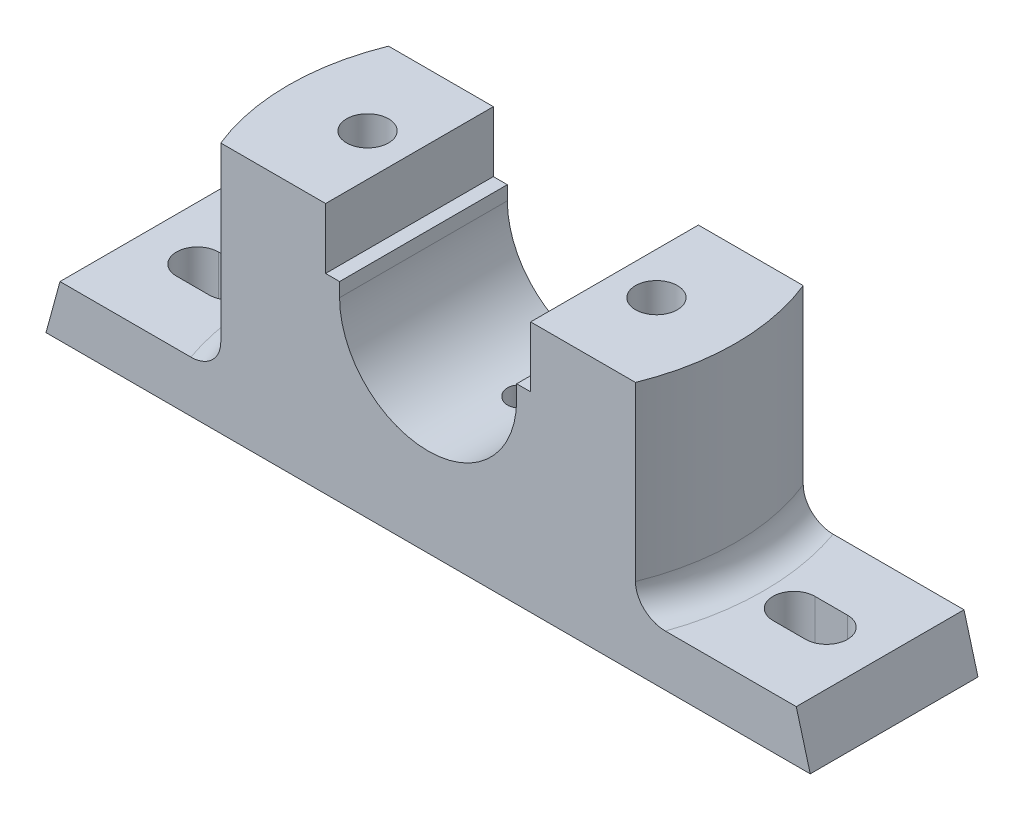
from build123d import *

# Parameters (mm, degrees)
BOSS_EXTRUDE1_DEPTH       = 18
CUT_EXTRUDE2_DEPTH        = 43
CUT_EXTRUDE3_DEPTH        = 11
SKETCH6_W                 = 20
SKETCH6_H                 = 20
CUT_EXTRUDE4_DEPTH        = 8
F_6_0MM_DOWEL_HOLE2_D     = 9
FILLET1_R                 = 6
FILLET2_R                 = 6
F_6_0MM_DOWEL_HOLE3_D     = 6
F_6_0MM_DOWEL_HOLE3_DEPTH = 6
F_6_0MM_DOWEL_HOLE3_TIP   = 1.802581857


with BuildPart() as part:
    # Sketch2 → Boss-Extrude1 (new, symmetric)
    with BuildSketch(Plane.XY):
        with BuildLine():
            Line((-82, 0), (82, 0))
            Line((82, 0), (79, 11))
            Line((79, 11), (50, 11))
            Line((50, 11), (50, 54))
            Line((50, 54), (22, 54))
            Line((22, 54), (22, 41))
            Line((22, 41), (19, 41))
            Line((19, 41), (19, 38))
            ThreePointArc((19, 38), (0, 19), (-19, 38))
            Line((-19, 38), (-19, 41))
            Line((-19, 41), (-22, 41))
            Line((-22, 41), (-22, 54))
            Line((-22, 54), (-50, 54))
            Line((-50, 54), (-50, 11))
            Line((-50, 11), (-79, 11))
            Line((-79, 11), (-82, 0))
        make_face()
    extrude(amount=BOSS_EXTRUDE1_DEPTH, both=True)

    # Sketch3 → Cut-Extrude2 (cut)
    with BuildSketch(Plane(origin=(0, 54, 0), x_dir=(1, 0, 0), z_dir=(0, 1, 0))):
        with BuildLine():
            Line((-44.497190923, -18), (-50, -18))
            Line((-50, -18), (-50, 18))
            Line((-50, 18), (-44.497190923, 18))
            ThreePointArc((-44.497190923, 18), (-48, 0), (-44.497190923, -18))
        make_face()
    cut_extrude2 = extrude(amount=-CUT_EXTRUDE2_DEPTH, mode=Mode.SUBTRACT)

    # Sketch4 → Cut-Extrude3 (cut)
    with BuildSketch(Plane(origin=(0, 11, 0), x_dir=(1, 0, 0), z_dir=(0, 1, 0))):
        with BuildLine():
            Line((-67.5, 4.5), (-60.5, 4.5))
            ThreePointArc((-60.5, 4.5), (-56, 0), (-60.5, -4.5))
            Line((-60.5, -4.5), (-67.5, -4.5))
            ThreePointArc((-67.5, -4.5), (-72, 0), (-67.5, 4.5))
        make_face()
    cut_extrude3 = extrude(amount=-CUT_EXTRUDE3_DEPTH, mode=Mode.SUBTRACT)

    # Sketch6 → Cut-Extrude4 (cut)
    with BuildSketch(Plane.XZ):
        with Locations((-31, 0)):
            Rectangle(SKETCH6_W, SKETCH6_H)
    cut_extrude4 = extrude(amount=-CUT_EXTRUDE4_DEPTH, mode=Mode.SUBTRACT)

    # Ø6.0mm Dowel Hole2 (through all)
    with Locations(Plane(origin=(0, 8, 0), x_dir=(-1, 0, 0), z_dir=(0, -1, 0))):
        with Locations((31, 0)):
            f_6_0mm_dowel_hole2 = Hole(F_6_0MM_DOWEL_HOLE2_D / 2)

    # Mirror2: Cut-Extrude2, Cut-Extrude3, Cut-Extrude4, Ø6.0mm Dowel Hole2 across plane
    add(cut_extrude2.mirror(Plane(origin=(0, 0, 0), x_dir=(0, 0, 1), z_dir=(1, 0, 0))), mode=Mode.SUBTRACT)
    add(cut_extrude3.mirror(Plane(origin=(0, 0, 0), x_dir=(0, 0, 1), z_dir=(1, 0, 0))), mode=Mode.SUBTRACT)
    add(cut_extrude4.mirror(Plane(origin=(0, 0, 0), x_dir=(0, 0, 1), z_dir=(1, 0, 0))), mode=Mode.SUBTRACT)
    add(f_6_0mm_dowel_hole2.mirror(Plane(origin=(0, 0, 0), x_dir=(0, 0, 1), z_dir=(1, 0, 0))), mode=Mode.SUBTRACT)

    # Fillet1
    fillet1_edges = [part.edges().sort_by_distance(p)[0] for p in [
        (48, 11, 0),
    ]]
    fillet(fillet1_edges, radius=FILLET1_R)

    # Fillet2
    fillet2_edges = [part.edges().sort_by_distance(p)[0] for p in [
        (-48, 11, 0),
    ]]
    fillet(fillet2_edges, radius=FILLET2_R)

    # Ø6.0mm Dowel Hole3
    with Locations(Plane(origin=(0, 19, -2.049394215), x_dir=(1, 0, 0), z_dir=(0, 1, 0))):
        with Locations((0, 0)):
            Hole(F_6_0MM_DOWEL_HOLE3_D / 2, depth=F_6_0MM_DOWEL_HOLE3_DEPTH)
            with Locations((0, 0, -(F_6_0MM_DOWEL_HOLE3_DEPTH + F_6_0MM_DOWEL_HOLE3_TIP / 2))):  # 118° drill point
                Cone(0, F_6_0MM_DOWEL_HOLE3_D / 2, F_6_0MM_DOWEL_HOLE3_TIP, mode=Mode.SUBTRACT)


solid = part.part
